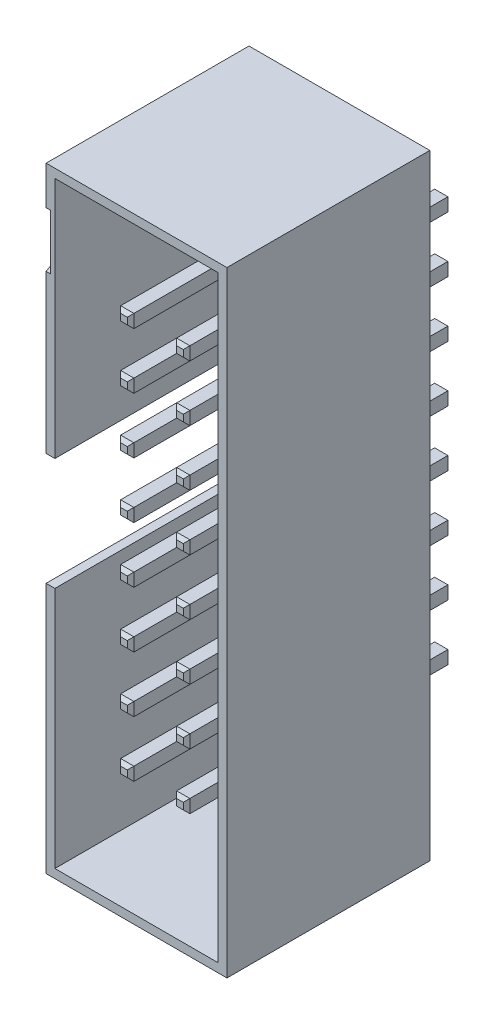
from build123d import *

# Parameters (mm, degrees)
ESQUISSE1_W             = 8.2
ESQUISSE1_H             = 27.9
BOSS_EXTRU_1_DEPTH      = 9.2
ESQUISSE2_W             = 7.4
ESQUISSE2_H             = 27.1
ENL_V_MAT_EXTRU_1_DEPTH = 8
ESQUISSE3_W             = 0.6
ESQUISSE3_H             = 0.6
BOSS_EXTRU_2_DEPTH      = 3.5
BOSS_EXTRU_2_DEPTH_BACK = 8.5
CHANFREIN1_SIZE         = 0.15
ESQUISSE4_W             = 0.4
ESQUISSE4_H             = 5.1
ENL_V_MAT_EXTRU_2_DEPTH = 8
ENL_V_MAT_EXTRU_3_DEPTH = 0.2


with BuildPart() as part:
    # Esquisse1 → Boss.-Extru.1 (new body)
    with BuildSketch(Plane.XY):
        with Locations((4.1, 13.95)):
            Rectangle(ESQUISSE1_W, ESQUISSE1_H)
    extrude(amount=BOSS_EXTRU_1_DEPTH)

    # Esquisse2 → Enlèv. mat.-Extru.1 (cut)
    with BuildSketch(Plane.XY.offset(9.2)):
        with Locations((4.1, 13.95)):
            Rectangle(ESQUISSE2_W, ESQUISSE2_H)
    extrude(amount=-ENL_V_MAT_EXTRU_1_DEPTH, mode=Mode.SUBTRACT)

    # Esquisse3 → Boss.-Extru.2 (add, two sides)
    with BuildSketch(Plane(origin=(0, 0, 0), x_dir=(-1, 0, 0), z_dir=(0, 0, -1))) as boss_extru_2_sk:
        with Locations((-5.37, 22.84)):
            Rectangle(ESQUISSE3_W, ESQUISSE3_H)
        with Locations((-2.83, 22.84)):
            Rectangle(ESQUISSE3_W, ESQUISSE3_H)
        with Locations((-5.37, 20.3)):
            Rectangle(ESQUISSE3_W, ESQUISSE3_H)
        with Locations((-2.83, 20.3)):
            Rectangle(ESQUISSE3_W, ESQUISSE3_H)
        with Locations((-5.37, 17.76)):
            Rectangle(ESQUISSE3_W, ESQUISSE3_H)
        with Locations((-2.83, 17.76)):
            Rectangle(ESQUISSE3_W, ESQUISSE3_H)
        with Locations((-5.37, 15.22)):
            Rectangle(ESQUISSE3_W, ESQUISSE3_H)
        with Locations((-2.83, 15.22)):
            Rectangle(ESQUISSE3_W, ESQUISSE3_H)
        with Locations((-5.37, 12.68)):
            Rectangle(ESQUISSE3_W, ESQUISSE3_H)
        with Locations((-2.83, 12.68)):
            Rectangle(ESQUISSE3_W, ESQUISSE3_H)
        with Locations((-5.37, 10.14)):
            Rectangle(ESQUISSE3_W, ESQUISSE3_H)
        with Locations((-2.83, 10.14)):
            Rectangle(ESQUISSE3_W, ESQUISSE3_H)
        with Locations((-5.37, 7.6)):
            Rectangle(ESQUISSE3_W, ESQUISSE3_H)
        with Locations((-2.83, 7.6)):
            Rectangle(ESQUISSE3_W, ESQUISSE3_H)
        with Locations((-5.37, 5.06)):
            Rectangle(ESQUISSE3_W, ESQUISSE3_H)
        with Locations((-2.83, 5.06)):
            Rectangle(ESQUISSE3_W, ESQUISSE3_H)
    extrude(amount=BOSS_EXTRU_2_DEPTH)
    extrude(boss_extru_2_sk.sketch, amount=-BOSS_EXTRU_2_DEPTH_BACK)

    # Chanfrein1
    chanfrein1_edges = [part.edges().sort_by_distance(p)[0] for p in [
        (5.07, 17.76, 8.5),
        (5.37, 17.46, 8.5),
        (5.67, 17.76, 8.5),
        (5.37, 18.06, 8.5),
        (5.07, 17.76, -3.5),
        (5.37, 18.06, -3.5),
        (5.67, 17.76, -3.5),
        (5.37, 17.46, -3.5),
        (2.53, 17.76, 8.5),
        (2.83, 17.46, 8.5),
        (3.13, 17.76, 8.5),
        (2.83, 18.06, 8.5),
        (2.53, 17.76, -3.5),
        (2.83, 18.06, -3.5),
        (3.13, 17.76, -3.5),
        (2.83, 17.46, -3.5),
        (5.07, 15.22, 8.5),
        (5.37, 14.92, 8.5),
        (5.67, 15.22, 8.5),
        (5.37, 15.52, 8.5),
        (5.07, 15.22, -3.5),
        (5.37, 15.52, -3.5),
        (5.67, 15.22, -3.5),
        (5.37, 14.92, -3.5),
        (2.53, 15.22, 8.5),
        (2.83, 14.92, 8.5),
        (3.13, 15.22, 8.5),
        (2.83, 15.52, 8.5),
        (2.53, 15.22, -3.5),
        (2.83, 15.52, -3.5),
        (3.13, 15.22, -3.5),
        (2.83, 14.92, -3.5),
        (5.07, 12.68, 8.5),
        (5.37, 12.38, 8.5),
        (5.67, 12.68, 8.5),
        (5.37, 12.98, 8.5),
        (5.07, 12.68, -3.5),
        (5.37, 12.98, -3.5),
        (5.67, 12.68, -3.5),
        (5.37, 12.38, -3.5),
        (2.53, 12.68, 8.5),
        (2.83, 12.38, 8.5),
        (3.13, 12.68, 8.5),
        (2.83, 12.98, 8.5),
        (2.53, 12.68, -3.5),
        (2.83, 12.98, -3.5),
        (3.13, 12.68, -3.5),
        (2.83, 12.38, -3.5),
        (5.07, 10.14, 8.5),
        (5.37, 9.84, 8.5),
        (5.67, 10.14, 8.5),
        (5.37, 10.44, 8.5),
        (5.07, 10.14, -3.5),
        (5.37, 10.44, -3.5),
        (5.67, 10.14, -3.5),
        (5.37, 9.84, -3.5),
        (2.53, 10.14, 8.5),
        (2.83, 9.84, 8.5),
        (3.13, 10.14, 8.5),
        (2.83, 10.44, 8.5),
        (2.53, 10.14, -3.5),
        (2.83, 10.44, -3.5),
        (3.13, 10.14, -3.5),
        (2.83, 9.84, -3.5),
        (5.07, 7.6, 8.5),
        (5.37, 7.3, 8.5),
        (5.67, 7.6, 8.5),
        (5.37, 7.9, 8.5),
        (5.07, 7.6, -3.5),
        (5.37, 7.9, -3.5),
        (5.67, 7.6, -3.5),
        (5.37, 7.3, -3.5),
        (2.53, 7.6, 8.5),
        (2.83, 7.3, 8.5),
        (3.13, 7.6, 8.5),
        (2.83, 7.9, 8.5),
        (2.53, 7.6, -3.5),
        (2.83, 7.9, -3.5),
        (3.13, 7.6, -3.5),
        (2.83, 7.3, -3.5),
        (5.07, 22.84, 8.5),
        (5.07, 5.06, 8.5),
        (5.37, 4.76, 8.5),
        (5.67, 5.06, 8.5),
        (5.37, 5.36, 8.5),
        (5.37, 22.54, 8.5),
        (5.07, 5.06, -3.5),
        (5.37, 5.36, -3.5),
        (5.67, 5.06, -3.5),
        (5.37, 4.76, -3.5),
        (5.67, 22.84, 8.5),
        (5.37, 23.14, 8.5),
        (2.53, 5.06, 8.5),
        (2.83, 4.76, 8.5),
        (3.13, 5.06, 8.5),
        (2.83, 5.36, 8.5),
        (2.53, 5.06, -3.5),
        (2.83, 5.36, -3.5),
        (3.13, 5.06, -3.5),
        (2.83, 4.76, -3.5),
        (5.07, 22.84, -3.5),
        (5.37, 23.14, -3.5),
        (5.67, 22.84, -3.5),
        (5.37, 22.54, -3.5),
        (2.53, 22.84, 8.5),
        (2.83, 22.54, 8.5),
        (3.13, 22.84, 8.5),
        (2.83, 23.14, 8.5),
        (2.53, 22.84, -3.5),
        (2.83, 23.14, -3.5),
        (3.13, 22.84, -3.5),
        (2.83, 22.54, -3.5),
        (5.07, 20.3, 8.5),
        (5.37, 20, 8.5),
        (5.67, 20.3, 8.5),
        (5.37, 20.6, 8.5),
        (5.07, 20.3, -3.5),
        (5.37, 20.6, -3.5),
        (5.67, 20.3, -3.5),
        (5.37, 20, -3.5),
        (2.53, 20.3, 8.5),
        (2.83, 20, 8.5),
        (3.13, 20.3, 8.5),
        (2.83, 20.6, 8.5),
        (2.53, 20.3, -3.5),
        (2.83, 20.6, -3.5),
        (3.13, 20.3, -3.5),
        (2.83, 20, -3.5),
    ]]
    chamfer(chanfrein1_edges, length=CHANFREIN1_SIZE)

    # Esquisse4 → Enlèv. mat.-Extru.2 (cut)
    with BuildSketch(Plane.XY.offset(9.2)):
        with Locations((0.2, 13.95)):
            Rectangle(ESQUISSE4_W, ESQUISSE4_H)
    extrude(amount=-ENL_V_MAT_EXTRU_2_DEPTH, mode=Mode.SUBTRACT)

    # Esquisse5 → Enlèv. mat.-Extru.3 (cut)
    with BuildSketch(Plane.ZY):
        Polygon((9.2, 26.15), (9.2, 23.65), (7.034936491, 24.9), align=None)
    extrude(amount=-ENL_V_MAT_EXTRU_3_DEPTH, mode=Mode.SUBTRACT)


solid = part.part
